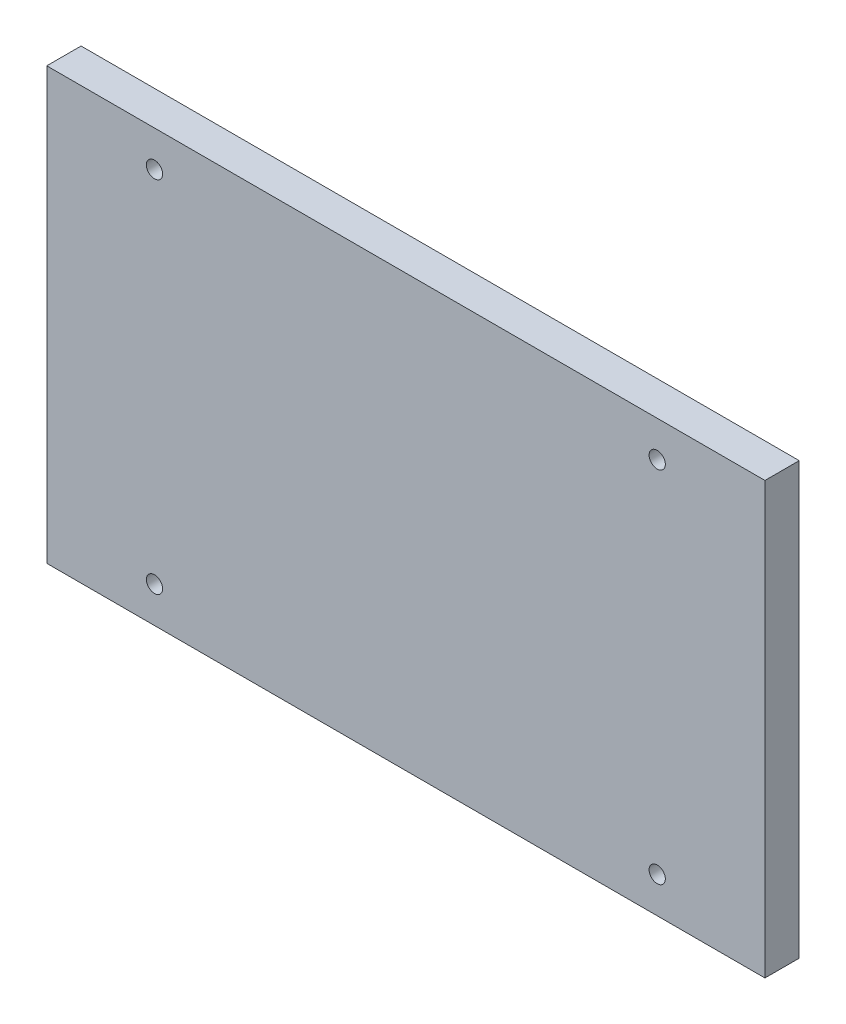
from build123d import *

# Parameters (mm, degrees)
SKETCH1_W             = 100
SKETCH1_H             = 60
SKETCH1_R             = 1.13
BOSS_EXTRUDE1_DEPTH   = 4.7752
F_4_40_TAPPED_HOLE1_D = 2.2606


with BuildPart() as part:
    # Sketch1 → Boss-Extrude1 (new body)
    with BuildSketch(Plane.XY):
        with Locations((50, -30)):
            Rectangle(SKETCH1_W, SKETCH1_H)
        with Locations((15, -5)):
            Circle(SKETCH1_R, mode=Mode.SUBTRACT)
        with Locations((15, -55)):
            Circle(SKETCH1_R, mode=Mode.SUBTRACT)
        with Locations((85, -5)):
            Circle(SKETCH1_R, mode=Mode.SUBTRACT)
        with Locations((85, -55)):
            Circle(SKETCH1_R, mode=Mode.SUBTRACT)
    extrude(amount=BOSS_EXTRUDE1_DEPTH)

    # #4-40 Tapped Hole1 (through all)
    with Locations(Plane(origin=(15, -5, 4.7752), x_dir=(1, 0, 0), z_dir=(0, 0, 1))):
        with Locations((0, 0), (0, -50), (70, -50), (70, 0)):
            Hole(F_4_40_TAPPED_HOLE1_D / 2)


solid = part.part
